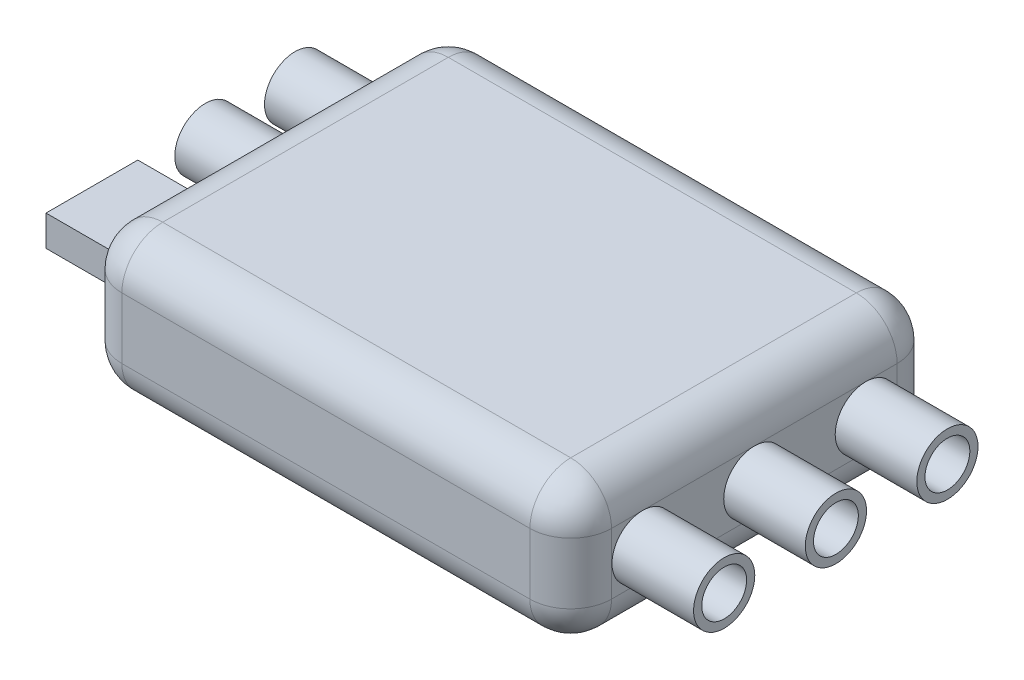
from build123d import *

# Parameters (mm, degrees)
BOSS_EXTRUDE1_DEPTH = 7
FILLET1_R           = 2
SKETCH2_R           = 1.5
SKETCH2_R_2         = 1.1
BOSS_EXTRUDE2_DEPTH = 4
SKETCH3_R           = 1.5
SKETCH3_R_2         = 1.1
SKETCH3_W           = 4.5
SKETCH3_H           = 1.5
BOSS_EXTRUDE3_DEPTH = 4


with BuildPart() as part:
    # Sketch1 → Boss-Extrude1 (new body)
    with BuildSketch(Plane(origin=(0, 0, 0), x_dir=(1, 0, 0), z_dir=(0, 1, 0))):
        with BuildLine():
            Line((10, -9), (-10, -9))
            ThreePointArc((-10, -9), (-11.414213562, -8.414213562), (-12, -7))
            Line((-12, -7), (-12, 7))
            ThreePointArc((-12, 7), (-11.414213562, 8.414213562), (-10, 9))
            Line((-10, 9), (10, 9))
            ThreePointArc((10, 9), (11.414213562, 8.414213562), (12, 7))
            Line((12, 7), (12, -7))
            ThreePointArc((12, -7), (11.414213562, -8.414213562), (10, -9))
        make_face()
    extrude(amount=BOSS_EXTRUDE1_DEPTH)

    # Fillet1
    fillet1_edges = [part.edges().sort_by_distance(p)[0] for p in [
        (12, 0, 0),
        (11.414213562, 0, 8.414213562),
        (0, 0, 9),
        (-11.414213562, 0, 8.414213562),
        (11.414213562, 7, 8.414213562),
        (12, 7, 0),
        (11.414213562, 7, -8.414213562),
        (0, 7, -9),
        (-11.414213562, 7, -8.414213562),
        (-12, 7, 0),
        (-11.414213562, 7, 8.414213562),
        (-12, 0, 0),
        (0, 7, 9),
        (-11.414213562, 0, -8.414213562),
        (0, 0, -9),
        (11.414213562, 0, -8.414213562),
    ]]
    fillet(fillet1_edges, radius=FILLET1_R)

    # Sketch2 → Boss-Extrude2 (add)
    with BuildSketch(Plane(origin=(12, 0, 0), x_dir=(0, 0, -1), z_dir=(1, 0, 0))):
        with Locations((0, 3.5)):
            Circle(SKETCH2_R)
        with Locations((0, 3.5)):
            Circle(SKETCH2_R_2, mode=Mode.SUBTRACT)
        with Locations((-5.476648667, 3.5)):
            Circle(SKETCH2_R)
        with Locations((-5.476648667, 3.5)):
            Circle(SKETCH2_R_2, mode=Mode.SUBTRACT)
        with Locations((5.464786958, 3.5)):
            Circle(SKETCH2_R)
        with Locations((5.464786958, 3.5)):
            Circle(SKETCH2_R_2, mode=Mode.SUBTRACT)
    extrude(amount=BOSS_EXTRUDE2_DEPTH)

    # Sketch3 → Boss-Extrude3 (add)
    with BuildSketch(Plane.ZY.offset(12)):
        with Locations((-1.091059361, 3.5)):
            Circle(SKETCH3_R)
        with Locations((-1.091059361, 3.5)):
            Circle(SKETCH3_R_2, mode=Mode.SUBTRACT)
        with Locations((-5.491059361, 3.5)):
            Circle(SKETCH3_R)
        with Locations((-5.491059361, 3.5)):
            Circle(SKETCH3_R_2, mode=Mode.SUBTRACT)
        with Locations((4.47030055, 3.5)):
            Rectangle(SKETCH3_W, SKETCH3_H)
    extrude(amount=BOSS_EXTRUDE3_DEPTH)


solid = part.part
